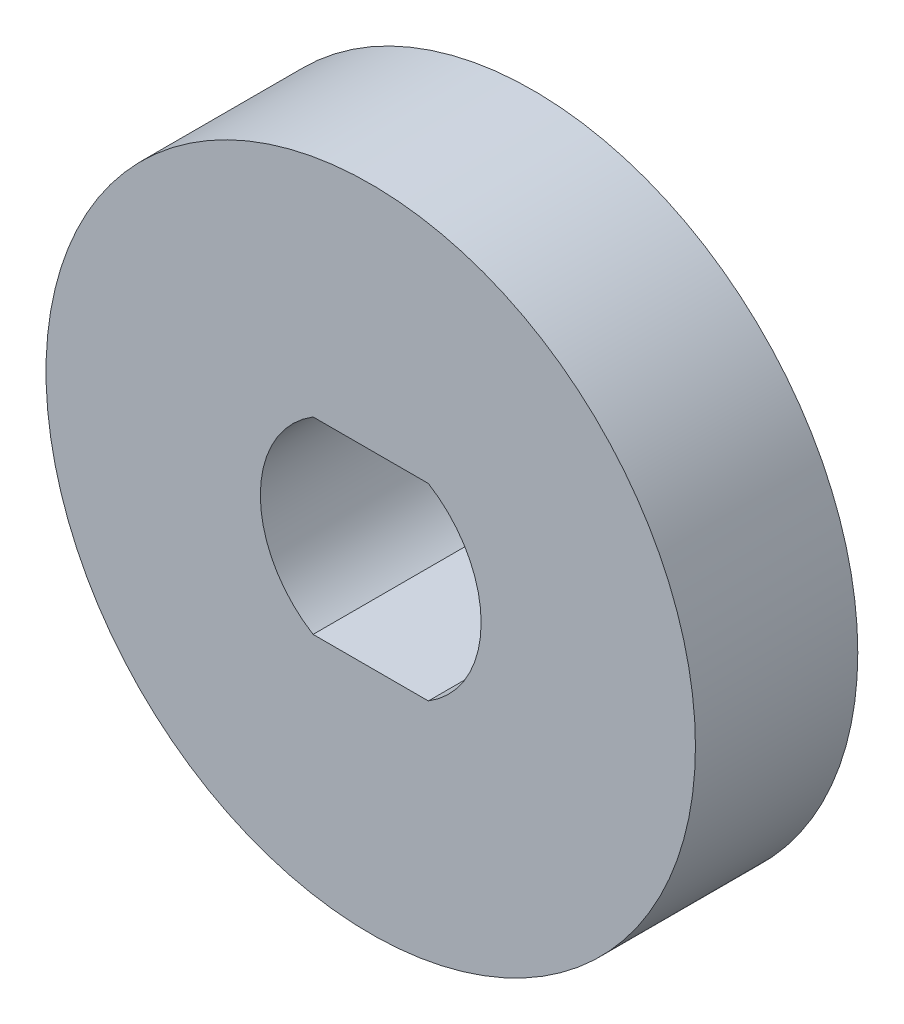
from build123d import *

# Parameters (mm, degrees)
SKETCH1_R           = 10
BOSS_EXTRUDE1_DEPTH = 5


with BuildPart() as part:
    # Sketch1 → Boss-Extrude1 (new body)
    with BuildSketch(Plane.XY):
        Circle(SKETCH1_R)
        with BuildLine():
            Line((-1.774823935, 2.9), (1.774823935, 2.9))
            ThreePointArc((1.774823935, 2.9), (3.4, 0), (1.774823935, -2.9))
            Line((1.774823935, -2.9), (-1.774823935, -2.9))
            ThreePointArc((-1.774823935, -2.9), (-3.4, 0), (-1.774823935, 2.9))
        make_face(mode=Mode.SUBTRACT)
    extrude(amount=BOSS_EXTRUDE1_DEPTH)


solid = part.part
